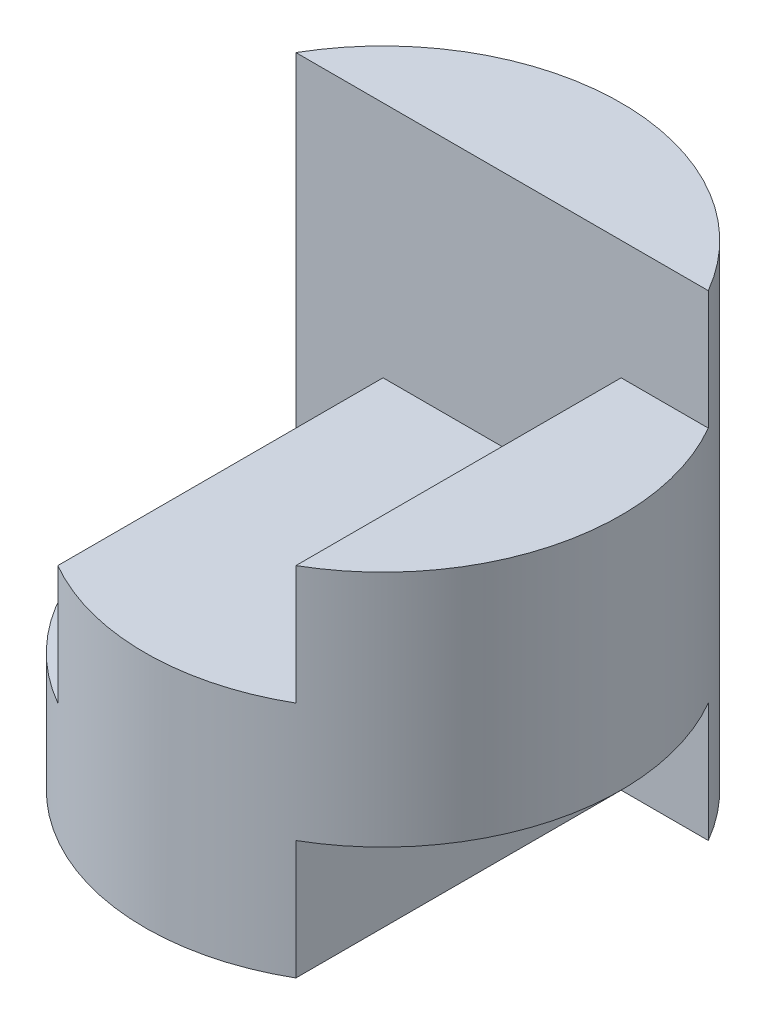
from build123d import *

# Parameters (mm, degrees)
SKETCH1_R               = 2
BOSS_EXTRUDE1_DEPTH     = 4
SKETCH2_W               = 1
SKETCH2_H               = 1
CUT_EXTRUDE1_DEPTH      = 3
CUT_EXTRUDE1_DEPTH_BACK = 1


with BuildPart() as part:
    # Sketch1 → Boss-Extrude1 (new body)
    with BuildSketch(Plane(origin=(0, 0, 0), x_dir=(1, 0, 0), z_dir=(0, 1, 0))):
        Circle(SKETCH1_R)
    extrude(amount=BOSS_EXTRUDE1_DEPTH)

    # Sketch2 → Cut-Extrude1 (cut, two sides)
    with BuildSketch(Plane.XY) as cut_extrude1_sk:
        Polygon((1, 4), (-2, 4), (-2, 3), (-2, 1), (-1, 1), (-1, 2), (1, 2), (1, 3), (2, 3), (2, 4), align=None)
        with Locations((1.5, 0.5)):
            Rectangle(SKETCH2_W, SKETCH2_H)
    extrude(amount=CUT_EXTRUDE1_DEPTH, mode=Mode.SUBTRACT)
    extrude(cut_extrude1_sk.sketch, amount=-CUT_EXTRUDE1_DEPTH_BACK, mode=Mode.SUBTRACT)


solid = part.part
